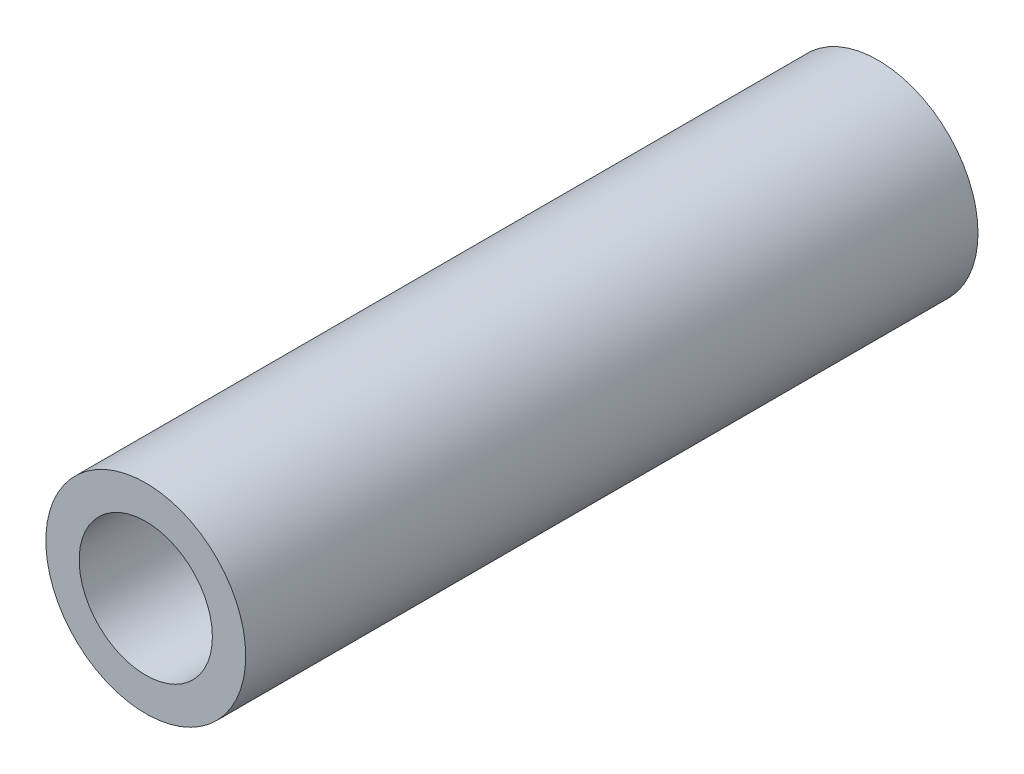
from build123d import *

# Parameters (mm, degrees)
BOSS_EXTRUDE1_START = 8.7249
SKETCH3_R           = 2.38125
BOSS_EXTRUDE1_DEPTH = 17.4498
CUT_EXTRUDE1_REACH  = 19.45
SKETCH4_R           = 1.5875


with BuildPart() as part:
    # Sketch3 → Boss-Extrude1 (new body)
    with BuildSketch(Plane.XY.offset(BOSS_EXTRUDE1_START)):
        Circle(SKETCH3_R)
    extrude(amount=-BOSS_EXTRUDE1_DEPTH)

    # Sketch4 → Cut-Extrude1 (cut, up to next)
    with BuildSketch(Plane.XY.offset(8.7249), mode=Mode.PRIVATE) as cut_extrude1_sk1:
        Circle(SKETCH4_R)
    cut_extrude1_tool1 = extrude(cut_extrude1_sk1.sketch, amount=-CUT_EXTRUDE1_REACH, mode=Mode.PRIVATE) & part.part
    add(cut_extrude1_tool1.solids().sort_by_distance((0, 0, 8.7249))[0], mode=Mode.SUBTRACT)


solid = part.part
